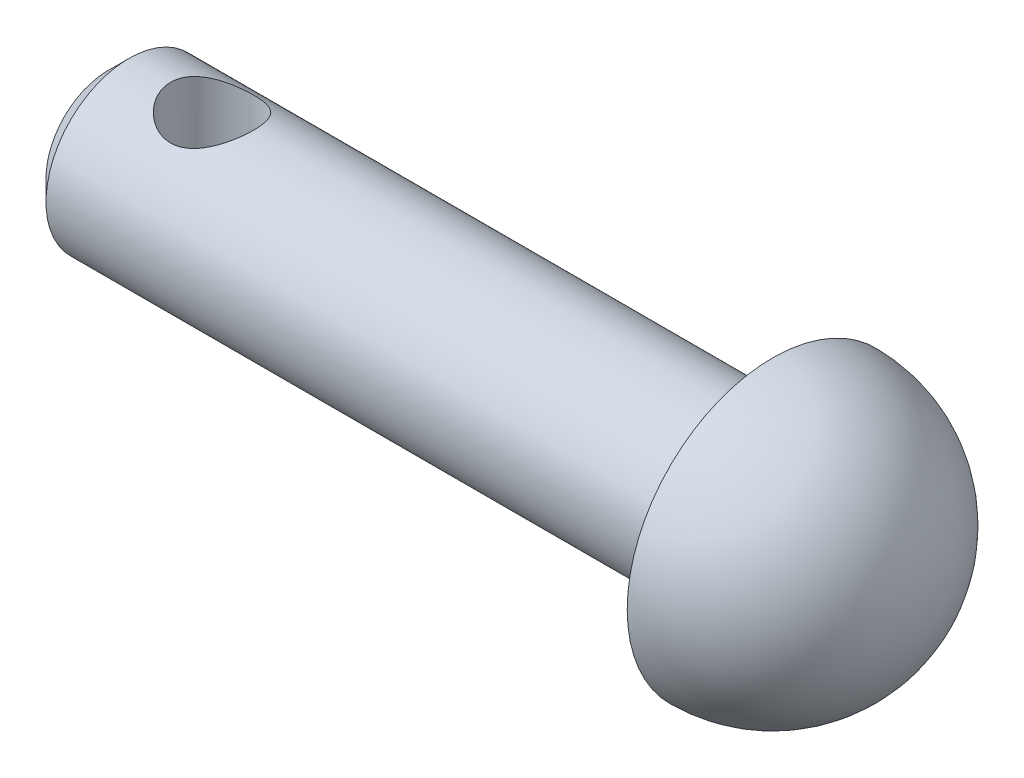
from build123d import *

# Parameters (mm, degrees)
SKETCH3_R               = 2
BOSS_EXTRUDE1_DEPTH     = 16
CHAMFER1_SIZE           = 0.5
SKETCH4_R               = 1
CUT_EXTRUDE1_DEPTH      = 3
CUT_EXTRUDE1_DEPTH_BACK = 3


with BuildPart() as part:
    # Sketch3 → Boss-Extrude1 (new body)
    with BuildSketch(Plane(origin=(0, 0, 0), x_dir=(0, 0, -1), z_dir=(1, 0, 0))):
        Circle(SKETCH3_R)
    extrude(amount=BOSS_EXTRUDE1_DEPTH)

    # Chamfer1
    chamfer1_edges = [part.edges().sort_by_distance(p)[0] for p in [
        (0, 0, 2),
    ]]
    chamfer(chamfer1_edges, length=CHAMFER1_SIZE)

    # Sketch4 → Cut-Extrude1 (cut, two sides)
    with BuildSketch(Plane(origin=(0, 0, 0), x_dir=(1, 0, 0), z_dir=(0, 1, 0))) as cut_extrude1_sk:
        with Locations((2.5, 0)):
            Circle(SKETCH4_R)
    extrude(amount=CUT_EXTRUDE1_DEPTH, mode=Mode.SUBTRACT)
    extrude(cut_extrude1_sk.sketch, amount=-CUT_EXTRUDE1_DEPTH_BACK, mode=Mode.SUBTRACT)

    # Sketch5 → Revolve1 (revolve)
    with BuildSketch(Plane(origin=(0, 0, 0), x_dir=(1, 0, 0), z_dir=(0, 1, 0))):
        with BuildLine():
            Line((16, 0), (16, 3.5))
            ThreePointArc((16, 3.5), (18.474873734, 2.474873734), (19.5, 0))
            Line((19.5, 0), (16, 0))
        make_face()
    revolve(axis=Axis((16, 0, 0), (1, 0, 0)))


solid = part.part
